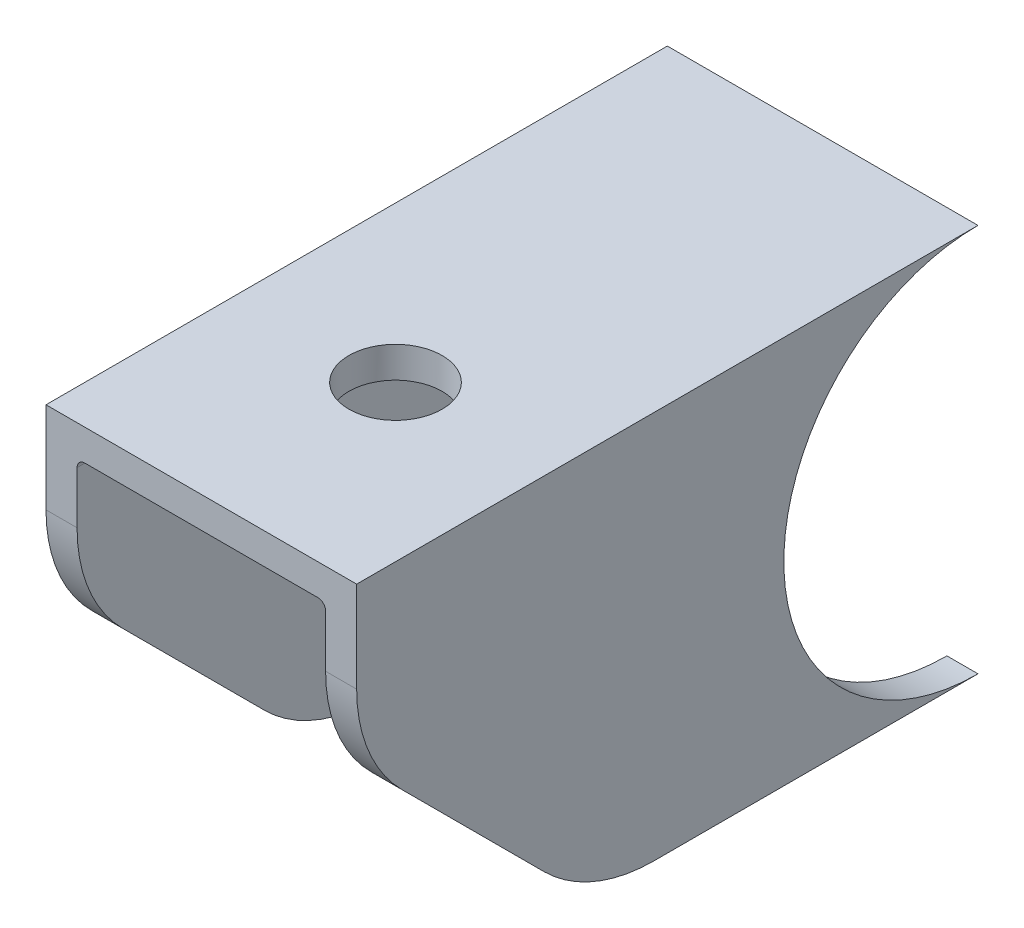
from build123d import *

# Parameters (mm, degrees)
DODANIE_WYCI_GNI_CIE1_DEPTH = 10
SKORUPA1_T                  = -2
ZAOKR_GLENIE1_R             = 0.5
SZKIC2_R                    = 3
WYTNIJ_WYCI_GNI_CIE1_DEPTH  = 10


with BuildPart() as part:
    # Szkic1 → Dodanie-wyciągnięcie1 (new body, symmetric)
    with BuildSketch(Plane(origin=(0, 0, 0), x_dir=(0, 0, -1), z_dir=(1, 0, 0))):
        with BuildLine():
            Line((0, -25), (-20.857864376, -25))
            ThreePointArc((-20.857864376, -25), (-24.6846987, -24.238795325), (-27.928932188, -22.071067812))
            Line((-27.928932188, -22.071067812), (-37.071067812, -12.928932188))
            ThreePointArc((-37.071067812, -12.928932188), (-39.238795325, -9.6846987), (-40, -5.857864376))
            Line((-40, -5.857864376), (-40, 0))
            Line((-40, 0), (0, 0))
            ThreePointArc((0, 0), (-12.5, -12.5), (0, -25))
        make_face()
    extrude(amount=DODANIE_WYCI_GNI_CIE1_DEPTH, both=True)

    # Skorupa1
    skorupa1_openings = [part.faces().sort_by_distance(p)[0] for p in [
        (0, -25, 10.428932188),
        (0, -23.887164616, 24.539048491),
        (0, -17.5, 32.5),
        (0, -9.539048491, 38.887164616),
        (0, -2.928932188, 40),
        (0, -12.5, 6.25),
    ]]
    offset(amount=SKORUPA1_T, openings=skorupa1_openings, kind=Kind.INTERSECTION)

    # Zaokrąglenie1
    zaokr_glenie1_edges = [part.edges().sort_by_distance(p)[0] for p in [
        (-8, -2, 23.391164992),
        (8, -2, 23.391164992),
    ]]
    fillet(zaokr_glenie1_edges, radius=ZAOKR_GLENIE1_R)

    # Szkic2 → Wytnij-wyciągnięcie1 (cut)
    with BuildSketch(Plane(origin=(0, 0, 0), x_dir=(1, 0, 0), z_dir=(0, 1, 0))):
        with Locations((0, -27.5)):
            Circle(SZKIC2_R)
    extrude(amount=-WYTNIJ_WYCI_GNI_CIE1_DEPTH, mode=Mode.SUBTRACT)


solid = part.part
